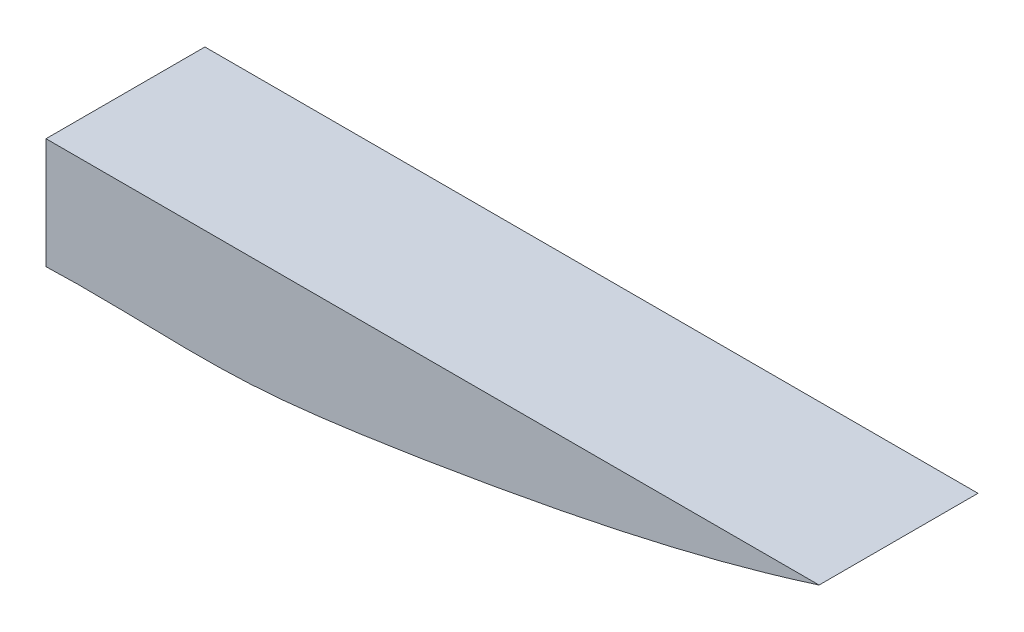
from build123d import *

# Parameters (mm, degrees)
BOSS_EXTRUDE1_DEPTH = 21.5


with BuildPart() as part:
    # Sketch1 → Boss-Extrude1 (new body)
    with BuildSketch(Plane.XY):
        with BuildLine():
            Line((0, 0), (0, -15))
            add(Edge.make_bspline(
                [(0, -15), (8.7220986, -14.653376105), (23.167933869, -15.833799228), (42.395480636, -13.459861479), (68.690557596, -9.207790335), (89.267936531, -4.902923832), (104.6, 0)],
                knots=[0, 0, 0, 0, 0.246872266, 0.406938063, 0.546001011, 1, 1, 1, 1], degree=3))
            Line((104.6, 0), (0, 0))
        make_face()
    extrude(amount=-BOSS_EXTRUDE1_DEPTH)


solid = part.part
